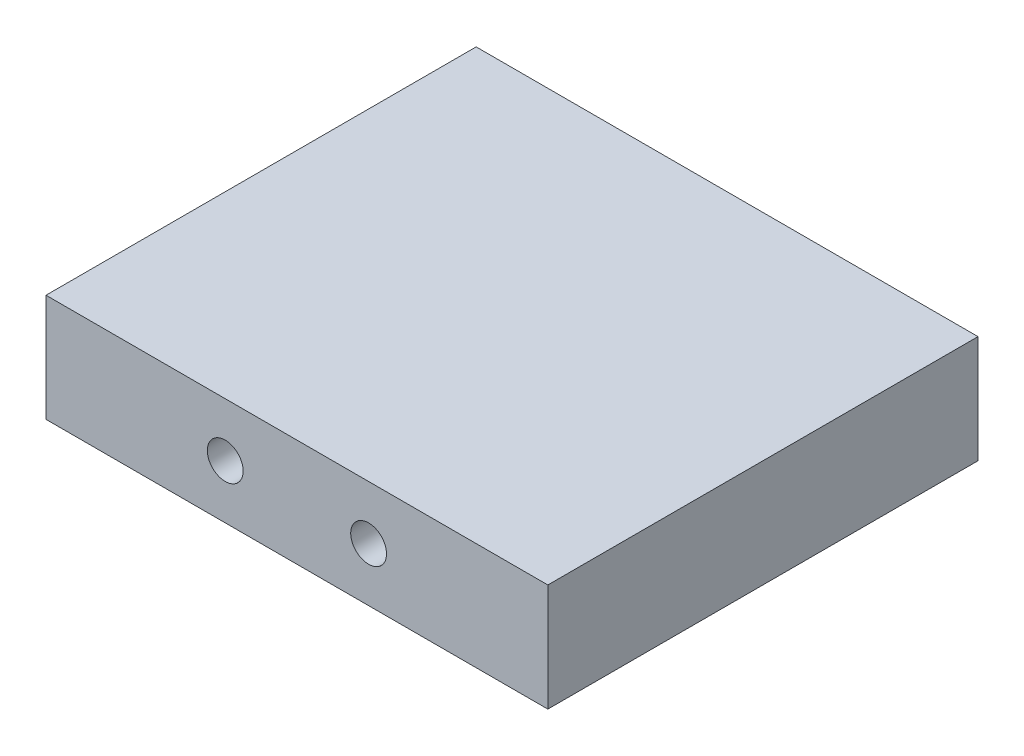
from build123d import *

# Parameters (mm, degrees)
SKETCH1_W           = 88.9
SKETCH1_H           = 76.2
BOSS_EXTRUDE1_DEPTH = 19.05
SKETCH2_R           = 3.175
CUT_EXTRUDE1_DEPTH  = 12.7


with BuildPart() as part:
    # Sketch1 → Boss-Extrude1 (new body)
    with BuildSketch(Plane(origin=(0, 0, 0), x_dir=(1, 0, 0), z_dir=(0, 1, 0))):
        Rectangle(SKETCH1_W, SKETCH1_H)
    extrude(amount=BOSS_EXTRUDE1_DEPTH)

    # Sketch2 → Cut-Extrude1 (cut)
    with BuildSketch(Plane.XY.offset(38.1)):
        with Locations((-12.7, 9.525)):
            Circle(SKETCH2_R)
        with Locations((12.7, 9.525)):
            Circle(SKETCH2_R)
    extrude(amount=-CUT_EXTRUDE1_DEPTH, mode=Mode.SUBTRACT)


solid = part.part
